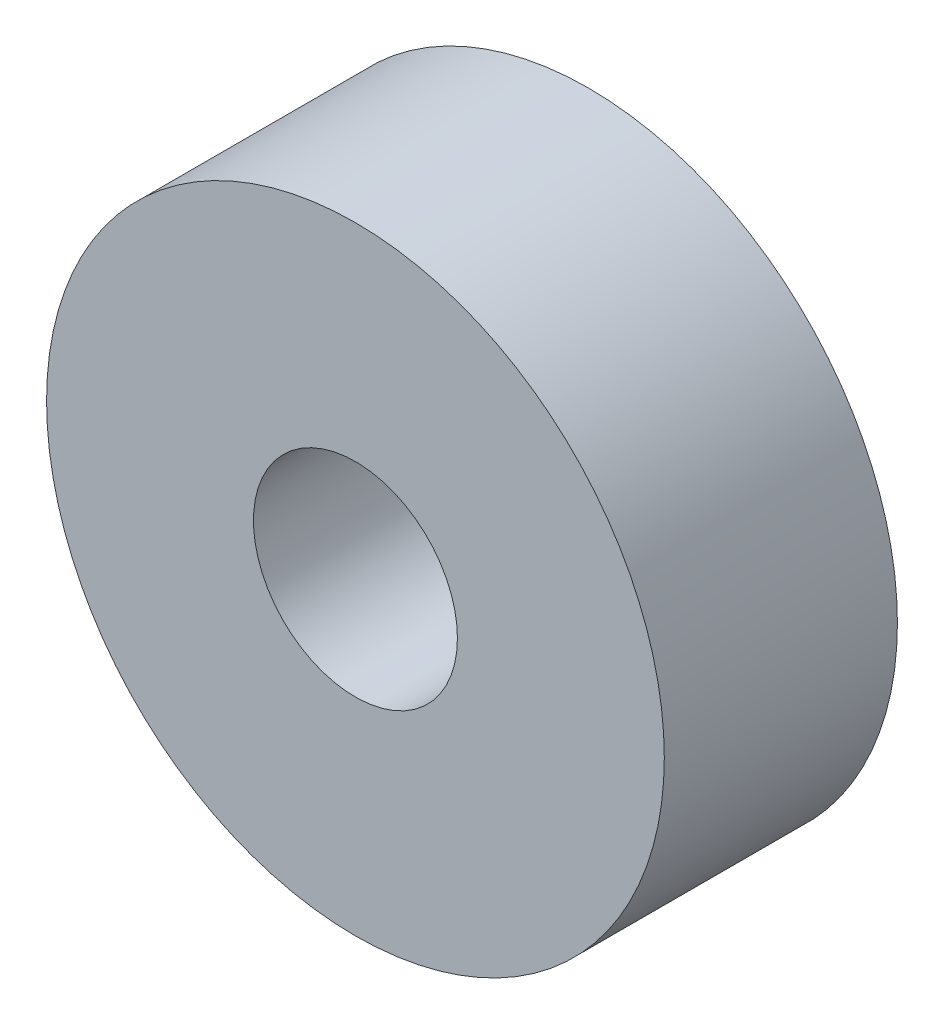
from build123d import *

# Parameters (mm, degrees)
SKETCH_1_R      = 106
SKETCH_1_R_2    = 35
EXTRUDE_1_DEPTH = 80


with BuildPart() as part:
    # Эскиз1 → Бобышка-Вытянуть1 (new body)
    with BuildSketch(Plane.XY):
        Circle(SKETCH_1_R)
        Circle(SKETCH_1_R_2, mode=Mode.SUBTRACT)
    extrude(amount=EXTRUDE_1_DEPTH)


solid = part.part
